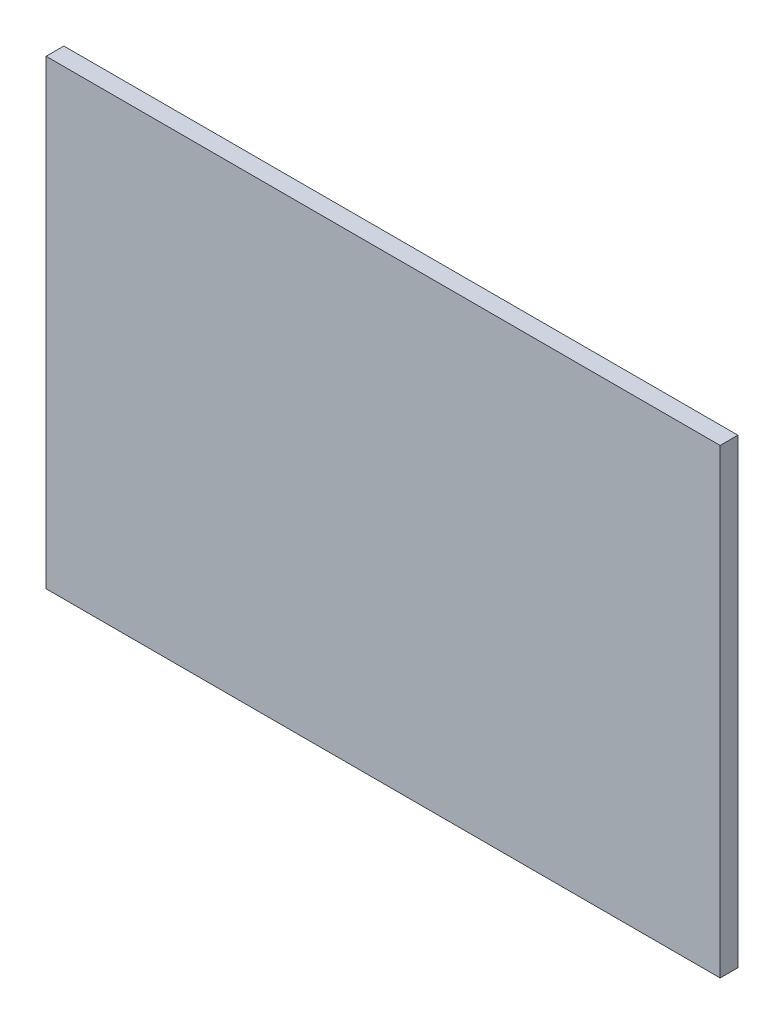
from build123d import *

# Parameters (mm, degrees)
SKETCH1_W           = 38
SKETCH1_H           = 26
BOSS_EXTRUDE1_DEPTH = 1


with BuildPart() as part:
    # Sketch1 → Boss-Extrude1 (new body)
    with BuildSketch(Plane.XY):
        Rectangle(SKETCH1_W, SKETCH1_H)
    extrude(amount=BOSS_EXTRUDE1_DEPTH)


solid = part.part
